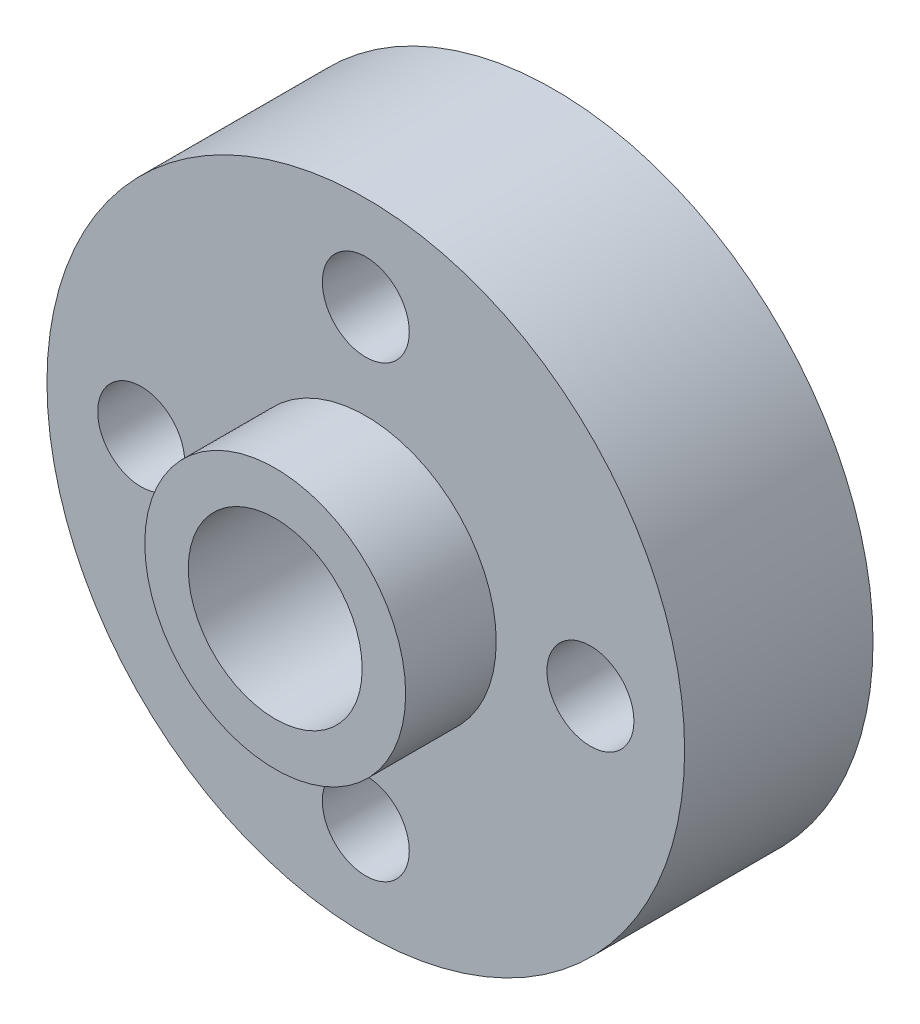
from build123d import *

# Parameters (mm, degrees)
ESQUISSE1_R             = 11
ESQUISSE1_R_2           = 3
EXTRUSION1_DEPTH        = 6.5
ESQUISSE3_R             = 4.5
ESQUISSE3_R_2           = 3
EXTRUSION2_DEPTH        = 3.125
ESQUISSE4_R             = 4.5
ESQUISSE4_R_2           = 3
EXTRUSION3_DEPTH        = 3.125
ENL_V_MAT_EXTRU_1_REACH = 11.625
ESQUISSE5_R             = 1.5


with BuildPart() as part:
    # Esquisse1 → Extrusion1 (new body)
    with BuildSketch(Plane.XY):
        Circle(ESQUISSE1_R)
        Circle(ESQUISSE1_R_2, mode=Mode.SUBTRACT)
    extrude(amount=EXTRUSION1_DEPTH)

    # Esquisse3 → Extrusion2 (add)
    with BuildSketch(Plane.XY.offset(6.5)):
        Circle(ESQUISSE3_R)
        Circle(ESQUISSE3_R_2, mode=Mode.SUBTRACT)
    extrude(amount=EXTRUSION2_DEPTH)

    # Esquisse4 → Extrusion3 (add)
    with BuildSketch(Plane(origin=(0, 0, 0), x_dir=(-1, 0, 0), z_dir=(0, 0, -1))):
        Circle(ESQUISSE4_R)
        Circle(ESQUISSE4_R_2, mode=Mode.SUBTRACT)
    extrude(amount=EXTRUSION3_DEPTH)

    # Esquisse5 → Enlèv. mat.-Extru.1 (cut, up to next)
    with BuildSketch(Plane.XY.offset(6.5), mode=Mode.PRIVATE) as enl_v_mat_extru_1_sk1:
        with Locations((0, 7.75)):
            Circle(ESQUISSE5_R)
    enl_v_mat_extru_1_tool1 = extrude(enl_v_mat_extru_1_sk1.sketch, amount=-ENL_V_MAT_EXTRU_1_REACH, mode=Mode.PRIVATE) & part.part
    add(enl_v_mat_extru_1_tool1.solids().sort_by_distance((0, 7.75, 6.5))[0], mode=Mode.SUBTRACT)
    # Esquisse5 → Enlèv. mat.-Extru.1 (cut, up to next)
    with BuildSketch(Plane.XY.offset(6.5), mode=Mode.PRIVATE) as enl_v_mat_extru_1_sk2:
        with Locations((0, -7.75)):
            Circle(ESQUISSE5_R)
    enl_v_mat_extru_1_tool2 = extrude(enl_v_mat_extru_1_sk2.sketch, amount=-ENL_V_MAT_EXTRU_1_REACH, mode=Mode.PRIVATE) & part.part
    add(enl_v_mat_extru_1_tool2.solids().sort_by_distance((0, -7.75, 6.5))[0], mode=Mode.SUBTRACT)
    # Esquisse5 → Enlèv. mat.-Extru.1 (cut, up to next)
    with BuildSketch(Plane.XY.offset(6.5), mode=Mode.PRIVATE) as enl_v_mat_extru_1_sk3:
        with Locations((-7.75, 0)):
            Circle(ESQUISSE5_R)
    enl_v_mat_extru_1_tool3 = extrude(enl_v_mat_extru_1_sk3.sketch, amount=-ENL_V_MAT_EXTRU_1_REACH, mode=Mode.PRIVATE) & part.part
    add(enl_v_mat_extru_1_tool3.solids().sort_by_distance((-7.75, 0, 6.5))[0], mode=Mode.SUBTRACT)
    # Esquisse5 → Enlèv. mat.-Extru.1 (cut, up to next)
    with BuildSketch(Plane.XY.offset(6.5), mode=Mode.PRIVATE) as enl_v_mat_extru_1_sk4:
        with Locations((7.75, 0)):
            Circle(ESQUISSE5_R)
    enl_v_mat_extru_1_tool4 = extrude(enl_v_mat_extru_1_sk4.sketch, amount=-ENL_V_MAT_EXTRU_1_REACH, mode=Mode.PRIVATE) & part.part
    add(enl_v_mat_extru_1_tool4.solids().sort_by_distance((7.75, 0, 6.5))[0], mode=Mode.SUBTRACT)


solid = part.part
